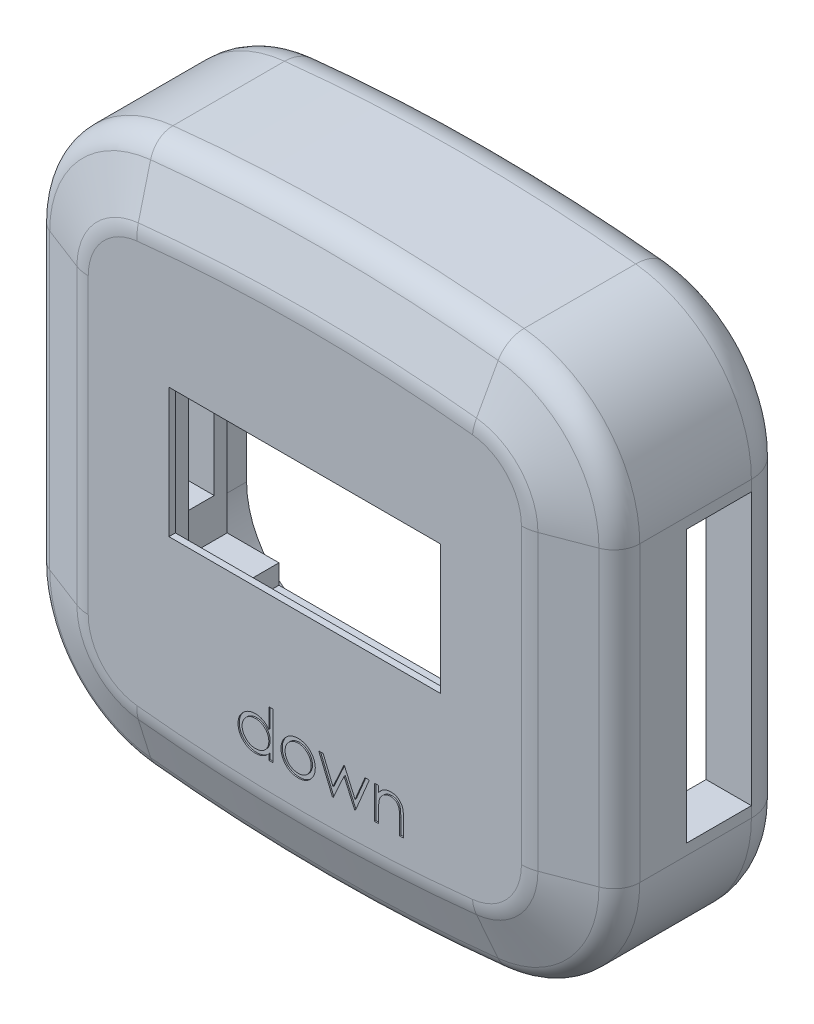
from build123d import *
from OCP.BRepFilletAPI import BRepFilletAPI_MakeChamfer

# Parameters (mm, degrees)
BOSS_EXTRU_1_DEPTH                   = 15
CONG_1_R                             = 3
CHANFREIN1_SIZE                      = 2
CHANFREIN1_SIZE2                     = 5.210178129
CONG_2_R                             = 3
CONG_3_R                             = 2
ENL_V_MAT_EXTRU_4_DEPTH              = 0.1
ESQUISSE3_W                          = 30
ESQUISSE3_H                          = 30
ENL_V_MAT_EXTRU_5_DEPTH              = 12
ESQUISSE10_W                         = 21
ESQUISSE10_H                         = 10
ENL_V_MAT_EXTRU_6_DEPTH              = 0.5
ESQUISSE9_W                          = 27
ESQUISSE9_H                          = 19.5
ENL_V_MAT_EXTRU_7_DEPTH              = 2.5
ENL_V_MAT_EXTRU_9_DEPTH              = 2
ESQUISSE15_W                         = 38
ESQUISSE15_H                         = 27
ENL_V_MAT_EXTRU_10_DEPTH             = 7
ENL_V_MAT_EXTRU_11_REACH             = 51.503
ESQUISSE16_W                         = 5
ESQUISSE16_H                         = 21
ENL_V_MAT_EXTRU_11_DIRECTION_2_REACH = 51.503


with BuildPart() as part:
    # Esquisse1 → Boss.-Extru.1 (new body)
    with BuildSketch(Plane.XY):
        with BuildLine():
            Line((-25.377842072, 10.899753086), (-25.377842072, -11.767388837))
            ThreePointArc((-25.377842072, -11.767388837), (-22.815336348, -18.451974007), (-16.441106293, -21.710701625))
            ThreePointArc((-16.441106293, -21.710701625), (-2.877842072, -22.433817876), (10.685422149, -21.710701625))
            ThreePointArc((10.685422149, -21.710701625), (17.059652204, -18.451974007), (19.622157928, -11.767388837))
            Line((19.622157928, -11.767388837), (19.622157928, 10.899753086))
            ThreePointArc((19.622157928, 10.899753086), (17.059652204, 17.584338256), (10.685422149, 20.843065874))
            ThreePointArc((10.685422149, 20.843065874), (-2.877842072, 21.566182124), (-16.441106293, 20.843065874))
            ThreePointArc((-16.441106293, 20.843065874), (-22.815336348, 17.584338256), (-25.377842072, 10.899753086))
        make_face()
    extrude(amount=BOSS_EXTRU_1_DEPTH)

    # Congé1
    cong_1_edges = [part.edges().sort_by_distance(p)[0] for p in [
        (-2.877842072, 21.566182124, 0),
        (17.059652204, 17.584338256, 0),
        (19.622157928, -0.433817876, 0),
        (17.059652204, -18.451974007, 0),
        (-2.877842072, -22.433817876, 0),
        (-22.815336348, -18.451974007, 0),
        (-25.377842072, -0.433817876, 0),
        (-22.815336348, 17.584338256, 0),
    ]]
    fillet(cong_1_edges, radius=CONG_1_R)

    # Chanfrein1: one chamfer whose edges measure the first distance from different faces: ONE call of the kernel's chamfer builder (chamfer() names one face for all edges)
    chanfrein1_edges_1 = [part.edges().sort_by_distance(p)[0] for p in [
        (-22.815336348, 17.584338256, 15),
    ]]
    chanfrein1_side_1 = [part.faces().sort_by_distance(p)[0] for p in [
        (-22.815336348, 17.584338256, 9),
    ]]
    chanfrein1_edges_2 = [part.edges().sort_by_distance(p)[0] for p in [
        (-25.377842072, -0.433817876, 15),
    ]]
    chanfrein1_side_2 = [part.faces().sort_by_distance(p)[0] for p in [
        (-25.377842072, -0.433817876, 9),
    ]]
    chanfrein1_edges_3 = [part.edges().sort_by_distance(p)[0] for p in [
        (-22.815336348, -18.451974007, 15),
    ]]
    chanfrein1_side_3 = [part.faces().sort_by_distance(p)[0] for p in [
        (-22.815336348, -18.451974007, 9),
    ]]
    chanfrein1_edges_4 = [part.edges().sort_by_distance(p)[0] for p in [
        (-2.877842072, -22.433817876, 15),
    ]]
    chanfrein1_side_4 = [part.faces().sort_by_distance(p)[0] for p in [
        (-2.877842072, -22.433817876, 9),
    ]]
    chanfrein1_edges_5 = [part.edges().sort_by_distance(p)[0] for p in [
        (17.059652204, -18.451974007, 15),
    ]]
    chanfrein1_side_5 = [part.faces().sort_by_distance(p)[0] for p in [
        (17.059652204, -18.451974007, 9),
    ]]
    chanfrein1_edges_6 = [part.edges().sort_by_distance(p)[0] for p in [
        (19.622157928, -0.433817876, 15),
    ]]
    chanfrein1_side_6 = [part.faces().sort_by_distance(p)[0] for p in [
        (19.622157928, -0.433817876, 9),
    ]]
    chanfrein1_edges_7 = [part.edges().sort_by_distance(p)[0] for p in [
        (17.059652204, 17.584338256, 15),
    ]]
    chanfrein1_side_7 = [part.faces().sort_by_distance(p)[0] for p in [
        (17.059652204, 17.584338256, 9),
    ]]
    chanfrein1_edges_8 = [part.edges().sort_by_distance(p)[0] for p in [
        (-2.877842072, 21.566182124, 15),
    ]]
    chanfrein1_side_8 = [part.faces().sort_by_distance(p)[0] for p in [
        (-2.877842072, 21.566182124, 9),
    ]]
    chanfrein1 = BRepFilletAPI_MakeChamfer(part.part.solid().wrapped)
    for e in chanfrein1_edges_1:
        chanfrein1.Add(CHANFREIN1_SIZE, CHANFREIN1_SIZE2, e.wrapped, chanfrein1_side_1[0].wrapped)  # the first distance lies on this face
    for e in chanfrein1_edges_2:
        chanfrein1.Add(CHANFREIN1_SIZE, CHANFREIN1_SIZE2, e.wrapped, chanfrein1_side_2[0].wrapped)  # the first distance lies on this face
    for e in chanfrein1_edges_3:
        chanfrein1.Add(CHANFREIN1_SIZE, CHANFREIN1_SIZE2, e.wrapped, chanfrein1_side_3[0].wrapped)  # the first distance lies on this face
    for e in chanfrein1_edges_4:
        chanfrein1.Add(CHANFREIN1_SIZE, CHANFREIN1_SIZE2, e.wrapped, chanfrein1_side_4[0].wrapped)  # the first distance lies on this face
    for e in chanfrein1_edges_5:
        chanfrein1.Add(CHANFREIN1_SIZE, CHANFREIN1_SIZE2, e.wrapped, chanfrein1_side_5[0].wrapped)  # the first distance lies on this face
    for e in chanfrein1_edges_6:
        chanfrein1.Add(CHANFREIN1_SIZE, CHANFREIN1_SIZE2, e.wrapped, chanfrein1_side_6[0].wrapped)  # the first distance lies on this face
    for e in chanfrein1_edges_7:
        chanfrein1.Add(CHANFREIN1_SIZE, CHANFREIN1_SIZE2, e.wrapped, chanfrein1_side_7[0].wrapped)  # the first distance lies on this face
    for e in chanfrein1_edges_8:
        chanfrein1.Add(CHANFREIN1_SIZE, CHANFREIN1_SIZE2, e.wrapped, chanfrein1_side_8[0].wrapped)  # the first distance lies on this face
    add(Compound.cast(chanfrein1.Shape()), mode=Mode.REPLACE)

    # Congé2
    cong_2_edges = [part.edges().sort_by_distance(p)[0] for p in [
        (13.184585203, 14.10155031, 15),
        (-2.877842072, 16.356003995, 15),
        (-18.940269346, 14.10155031, 15),
        (-20.167663943, -0.433817876, 15),
        (-18.940269346, -14.969186062, 15),
        (-2.877842072, -17.223639746, 15),
        (13.184585203, -14.969186062, 15),
        (14.411979799, -0.433817876, 15),
    ]]
    fillet(cong_2_edges, radius=CONG_2_R)

    # Congé3
    cong_3_edges = [part.edges().sort_by_distance(p)[0] for p in [
        (19.622157928, -0.433817876, 13),
        (17.059652204, -18.451974007, 13),
        (-2.877842072, -22.433817876, 13),
        (-22.815336348, -18.451974007, 13),
        (-25.377842072, -0.433817876, 13),
        (-22.815336348, 17.584338256, 13),
        (-2.877842072, 21.566182124, 13),
        (17.059652204, 17.584338256, 13),
    ]]
    fillet(cong_3_edges, radius=CONG_3_R)

    # Esquisse7 → Enlèv. mat.-Extru.4 (cut)
    with BuildSketch(Plane.XY.offset(15)):
        with BuildLine():
            Line((-5.346766398, -10.951246412), (-5.346766398, -14.540990002))
            Line((-5.346766398, -14.540990002), (-5.660868962, -14.540990002))
            Line((-5.660868962, -14.540990002), (-5.660868962, -14.098582149))
            add(Edge.make_bspline(
                [(-5.660868962, -14.098582149), (-5.696287753, -14.138621743), (-5.765407968, -14.216759514), (-5.880849086, -14.318841687), (-6.003217264, -14.403220008), (-6.131918585, -14.471369924), (-6.266836829, -14.52256198), (-6.407672916, -14.55894814), (-6.554484297, -14.582341975), (-6.654736652, -14.584677997), (-6.705540437, -14.585861797)],
                knots=[0, 0, 0, 0, 1.074387032, 2.096679803, 3.090159297, 4.057316773, 5.018401886, 5.985159533, 6.978961417, 8, 8, 8, 8], degree=3))
            add(Edge.make_bspline(
                [(-6.705540437, -14.585861797), (-6.750708391, -14.584635425), (-6.839781596, -14.582216964), (-6.970810673, -14.56345466), (-7.096902922, -14.533324039), (-7.218177495, -14.491423149), (-7.33384964, -14.435842328), (-7.444909737, -14.36930108), (-7.550782429, -14.29006025), (-7.649853968, -14.199472221), (-7.741085968, -14.101077234), (-7.821147241, -13.996131687), (-7.887900321, -13.885089383), (-7.943720401, -13.769356229), (-7.986716746, -13.64804131), (-8.01669038, -13.521564142), (-8.035430827, -13.390074268), (-8.037848288, -13.300534745), (-8.039074091, -13.25513263)],
                knots=[0, 0, 0, 0, 1.033919861, 2.038935746, 3.024066025, 3.998881131, 4.97069526, 5.957263378, 6.95902576, 7.993208707, 9.027059324, 10.027763471, 11.009749337, 11.988697705, 12.965288445, 13.950418724, 14.960734635, 16, 16, 16, 16], degree=3))
            add(Edge.make_bspline(
                [(-8.039074091, -13.25513263), (-8.037821119, -13.210668927), (-8.035344062, -13.122766583), (-8.016890843, -12.993487885), (-7.985859834, -12.868969625), (-7.942311986, -12.749612681), (-7.886470031, -12.635272631), (-7.818541944, -12.525868606), (-7.73852282, -12.421099209), (-7.646270413, -12.323427982), (-7.546335642, -12.233207368), (-7.439426912, -12.154798322), (-7.32820363, -12.087081473), (-7.21094062, -12.033427997), (-7.089373515, -11.990018892), (-6.962420069, -11.959985924), (-6.83060849, -11.942288603), (-6.741117998, -11.939725839), (-6.695724732, -11.938425899)],
                knots=[0, 0, 0, 0, 1.020392517, 2.01726096, 2.990465484, 3.961182959, 4.928053699, 5.906110375, 6.912531644, 7.948652711, 8.985773172, 9.998621852, 10.987621588, 11.969261332, 12.953316658, 13.946091881, 14.958173133, 16, 16, 16, 16], degree=3))
            add(Edge.make_bspline(
                [(-6.695724732, -11.938425899), (-6.643507924, -11.939992995), (-6.541012133, -11.943069031), (-6.391113612, -11.968775398), (-6.249326001, -12.011938276), (-6.114833014, -12.071029557), (-5.988436454, -12.147830308), (-5.869209813, -12.240581756), (-5.75922649, -12.351908902), (-5.694154668, -12.435520476), (-5.660868962, -12.478289681)],
                knots=[0, 0, 0, 0, 1.031072012, 2.023879775, 2.993683497, 3.952812103, 4.918022106, 5.908088563, 6.929940113, 8, 8, 8, 8], degree=3))
            Line((-5.660868962, -12.478289681), (-5.660868962, -10.951246412))
            Line((-5.660868962, -10.951246412), (-5.346766398, -10.951246412))
        make_face()
        with BuildLine():
            add(Edge.make_bspline(
                [(-6.691518001, -12.252528463), (-6.737432339, -12.254162101), (-6.828059939, -12.257386642), (-6.961103941, -12.282560137), (-7.088417355, -12.324444732), (-7.209363429, -12.381726633), (-7.322031646, -12.45375537), (-7.422725317, -12.540876753), (-7.512268018, -12.640713767), (-7.587576282, -12.752815877), (-7.648966779, -12.872993968), (-7.692133811, -12.998618407), (-7.720603059, -13.127423384), (-7.723511579, -13.21478607), (-7.724971527, -13.258638239)],
                knots=[0, 0, 0, 0, 1.031046209, 2.035121221, 3.029706178, 4.034933723, 5.034054252, 6.02443088, 7.017295772, 8.038157696, 9.050218397, 10.03989886, 11.016116709, 12, 12, 12, 12], degree=3))
            add(Edge.make_bspline(
                [(-7.724971527, -13.258638239), (-7.723106633, -13.302228346), (-7.719384156, -13.389237702), (-7.692633462, -13.518218279), (-7.647753589, -13.643872321), (-7.586511526, -13.765133314), (-7.509824901, -13.877717415), (-7.420936249, -13.979457537), (-7.318985967, -14.066947126), (-7.20605846, -14.140184699), (-7.08545049, -14.19934722), (-6.958616558, -14.24051286), (-6.82794092, -14.26709064), (-6.739088586, -14.270195117), (-6.694322488, -14.271759233)],
                knots=[0, 0, 0, 0, 0.979072187, 1.954306742, 2.945804271, 3.96968567, 4.997920485, 5.998718438, 6.996577872, 8.005894225, 9.015743152, 10.005417472, 10.995077863, 12, 12, 12, 12], degree=3))
            add(Edge.make_bspline(
                [(-6.694322488, -14.271759233), (-6.648875985, -14.270099269), (-6.558487399, -14.266797765), (-6.425048691, -14.2415165), (-6.295553728, -14.199747701), (-6.1717665, -14.141848575), (-6.056450369, -14.070091219), (-5.952952491, -13.986084128), (-5.865436523, -13.888380944), (-5.791243913, -13.781004491), (-5.733068496, -13.663292494), (-5.690692437, -13.537958303), (-5.665638531, -13.404997555), (-5.662480802, -13.314133628), (-5.660868962, -13.267752822)],
                knots=[0, 0, 0, 0, 1.01762866, 2.023962475, 3.030623092, 4.058876274, 5.077231937, 6.066672613, 7.034107872, 8.005628644, 8.981990164, 9.965428785, 10.961468474, 12, 12, 12, 12], degree=3))
            add(Edge.make_bspline(
                [(-5.660868962, -13.267752822), (-5.661828619, -13.232414992), (-5.663717526, -13.162858959), (-5.678148096, -13.060731441), (-5.701103022, -12.962997715), (-5.733449192, -12.869555026), (-5.775940477, -12.780920011), (-5.827188243, -12.69645625), (-5.888093692, -12.616603039), (-5.957676388, -12.542459968), (-6.033841591, -12.474833506), (-6.114436132, -12.414469265), (-6.200414879, -12.364880492), (-6.290331915, -12.323839221), (-6.38434325, -12.291180071), (-6.48321387, -12.269392377), (-6.585892857, -12.254432056), (-6.655938912, -12.253169675), (-6.691518001, -12.252528463)],
                knots=[0, 0, 0, 0, 1.050140795, 2.067009409, 3.05949893, 4.030605086, 5.00011959, 5.97591094, 6.962425594, 7.979863591, 8.993523472, 9.986985069, 10.967611495, 11.937549037, 12.921786183, 13.919465291, 14.943216303, 16, 16, 16, 16], degree=3))
        make_face(mode=Mode.SUBTRACT)
        with BuildLine():
            add(Edge.make_bspline(
                [(-3.393441078, -11.938425899), (-3.345449805, -11.93944779), (-3.251350647, -11.941451469), (-3.113542762, -11.962866435), (-2.981997626, -11.995613799), (-2.856211433, -12.040885361), (-2.737795138, -12.101567312), (-2.625023894, -12.173976603), (-2.518206885, -12.259759197), (-2.454183856, -12.326117265), (-2.42168627, -12.359800098)],
                knots=[0, 0, 0, 0, 1.054011418, 2.066658804, 3.057071809, 4.030435133, 4.997543892, 5.974964718, 6.972108034, 8, 8, 8, 8], degree=3))
            add(Edge.make_bspline(
                [(-2.42168627, -12.359800098), (-2.393704316, -12.392014084), (-2.338281936, -12.455818626), (-2.267216217, -12.559274239), (-2.205994657, -12.66641434), (-2.156931696, -12.778661666), (-2.118246672, -12.895036337), (-2.090780976, -13.015938349), (-2.074444041, -13.141100696), (-2.072241074, -13.226104534), (-2.071125373, -13.269155066)],
                knots=[0, 0, 0, 0, 1.025258237, 2.030674902, 3.01204498, 3.988269485, 4.97094183, 5.956517959, 6.965070386, 8, 8, 8, 8], degree=3))
            add(Edge.make_bspline(
                [(-2.071125373, -13.269155066), (-2.07210671, -13.312455124), (-2.074045878, -13.398018057), (-2.092389495, -13.524037423), (-2.120920581, -13.646232245), (-2.161752419, -13.764090939), (-2.214110528, -13.877973767), (-2.278001216, -13.987383316), (-2.353872833, -14.092535449), (-2.43987683, -14.192537287), (-2.534928706, -14.284703502), (-2.638044854, -14.365031772), (-2.747198888, -14.433853296), (-2.863842241, -14.489289712), (-2.986909728, -14.532999412), (-3.116666796, -14.563699429), (-3.252911866, -14.582261112), (-3.345939088, -14.584644686), (-3.393441078, -14.585861797)],
                knots=[0, 0, 0, 0, 0.998656419, 1.973391657, 2.932242238, 3.890759089, 4.846373663, 5.82037756, 6.809684879, 7.83454468, 8.860553229, 9.859544525, 10.845671541, 11.83227036, 12.833544569, 13.85385346, 14.904124723, 16, 16, 16, 16], degree=3))
            add(Edge.make_bspline(
                [(-3.393441078, -14.585861797), (-3.441175797, -14.584640601), (-3.534666657, -14.582248826), (-3.671392639, -14.563771543), (-3.801382258, -14.533013561), (-3.924610856, -14.489146068), (-4.041755703, -14.433851524), (-4.1515422, -14.365239835), (-4.254742116, -14.284679679), (-4.3498141, -14.192543742), (-4.435812706, -14.092533786), (-4.511685714, -13.987383748), (-4.57557604, -13.877973654), (-4.627934244, -13.764090969), (-4.668766057, -13.646232237), (-4.69729715, -13.524037425), (-4.715640764, -13.398018056), (-4.717579933, -13.312455123), (-4.71856127, -13.269155066)],
                knots=[0, 0, 0, 0, 1.099876186, 2.154163076, 3.173186993, 4.173200201, 5.163417411, 6.152872554, 7.150605724, 8.17532212, 9.198891216, 10.186952605, 11.159729845, 12.11414092, 13.071450619, 14.029093627, 15.002601286, 16, 16, 16, 16], degree=3))
            add(Edge.make_bspline(
                [(-4.71856127, -13.269155066), (-4.71743796, -13.22633852), (-4.715213998, -13.141569118), (-4.698893489, -13.016642057), (-4.671534933, -12.895944668), (-4.632803536, -12.780019192), (-4.583288345, -12.668263756), (-4.522927058, -12.560858925), (-4.451136425, -12.457871125), (-4.395934473, -12.394149044), (-4.368000373, -12.361903463)],
                knots=[0, 0, 0, 0, 1.031353054, 2.041901799, 3.029428768, 4.008703097, 4.981709435, 5.96992636, 6.972712378, 8, 8, 8, 8], degree=3))
            add(Edge.make_bspline(
                [(-4.368000373, -12.361903463), (-4.335551782, -12.327928524), (-4.271735918, -12.261110828), (-4.16438719, -12.175578304), (-4.051893369, -12.10166223), (-3.932168443, -12.042186015), (-3.806485585, -11.995347497), (-3.674266342, -11.962781982), (-3.535990827, -11.941528627), (-3.441431206, -11.939470449), (-3.393441078, -11.938425899)],
                knots=[0, 0, 0, 0, 1.027980169, 2.021703884, 2.998553061, 3.971491411, 4.943284454, 5.930300938, 6.949603206, 8, 8, 8, 8], degree=3))
        make_face()
        with BuildLine():
            add(Edge.make_bspline(
                [(-3.394843321, -12.252528463), (-3.428780933, -12.253493055), (-3.495780061, -12.255397338), (-3.594399646, -12.269881242), (-3.6893398, -12.292828746), (-3.780780644, -12.325432803), (-3.868413817, -12.367531702), (-3.952323219, -12.419240062), (-4.032755659, -12.479873018), (-4.108137722, -12.54933569), (-4.177320034, -12.625214684), (-4.237798011, -12.706063043), (-4.289223117, -12.79056939), (-4.332063276, -12.878821601), (-4.363970464, -12.971714015), (-4.387143487, -13.068194646), (-4.401613727, -13.168460062), (-4.403500106, -13.236621081), (-4.404458706, -13.271258431)],
                knots=[0, 0, 0, 0, 1.021534396, 2.016698045, 2.994645724, 3.958388632, 4.93408049, 5.916473867, 6.921342795, 7.962252576, 8.998418191, 10.008913653, 10.997312074, 11.973003931, 12.956656626, 13.948281152, 14.957379055, 16, 16, 16, 16], degree=3))
            add(Edge.make_bspline(
                [(-4.404458706, -13.271258431), (-4.402851882, -13.316010459), (-4.399662638, -13.404834864), (-4.373727402, -13.535645987), (-4.330341122, -13.661227839), (-4.271753842, -13.780844225), (-4.198347623, -13.891516503), (-4.111860557, -13.990187987), (-4.013220856, -14.075373799), (-3.903604356, -14.146054644), (-3.785250038, -14.2022144), (-3.659993717, -14.242013376), (-3.529353023, -14.267885068), (-3.440072292, -14.270456542), (-3.394843321, -14.271759233)],
                knots=[0, 0, 0, 0, 1.016792936, 2.018143844, 3.017858371, 4.030088057, 5.03801393, 6.028138512, 7.003788237, 7.991172063, 8.984598303, 9.972568034, 10.972917682, 12, 12, 12, 12], degree=3))
            add(Edge.make_bspline(
                [(-3.394843321, -14.271759233), (-3.349616953, -14.270448952), (-3.260341357, -14.267862496), (-3.12988218, -14.242143676), (-3.004968208, -14.202040015), (-2.88673682, -14.146117805), (-2.777170217, -14.07510539), (-2.677821096, -13.990669013), (-2.592072484, -13.891255162), (-2.51873888, -13.780697633), (-2.459192137, -13.661413281), (-2.416008935, -13.535622809), (-2.390011349, -13.404840767), (-2.38683052, -13.316012436), (-2.385227937, -13.271258431)],
                knots=[0, 0, 0, 0, 1.02726834, 2.027799167, 3.010890988, 4.004497153, 4.992059811, 5.971914811, 6.958719428, 7.966827853, 8.981595046, 9.981490638, 10.983022906, 12, 12, 12, 12], degree=3))
            add(Edge.make_bspline(
                [(-2.385227937, -13.271258431), (-2.386186207, -13.236620874), (-2.388071936, -13.168459448), (-2.4025469, -13.068196994), (-2.42570244, -12.971705398), (-2.457674057, -12.878853395), (-2.500328071, -12.79034089), (-2.552744864, -12.706311163), (-2.61297589, -12.624934617), (-2.682993011, -12.549580976), (-2.758296388, -12.47984594), (-2.838761427, -12.41921655), (-2.922546405, -12.367758955), (-3.009924988, -12.325072714), (-3.101377555, -12.293125374), (-3.196184685, -12.269748742), (-3.294383495, -12.255458546), (-3.361142538, -12.253511404), (-3.394843321, -12.252528463)],
                knots=[0, 0, 0, 0, 1.042956736, 2.052379634, 3.044323526, 4.02829302, 5.004299113, 5.996692471, 7.007513377, 8.048758398, 9.090003419, 10.095195979, 11.07790575, 12.047570684, 13.018257071, 13.989683339, 14.985167495, 16, 16, 16, 16], degree=3))
        make_face(mode=Mode.SUBTRACT)
        Polygon((-1.801894604, -11.983297694), (-1.46465502, -11.983297694), (-0.702535629, -13.823041284), (0.132500429, -11.983297694), (0.185785685, -11.983297694), (1.002592576, -13.823041284), (1.771723185, -11.983297694), (2.10195155, -11.983297694), (1.032740813, -14.540990002), (0.967536486, -14.540990002), (0.150028473, -12.701246412), (-0.684306462, -14.540990002), (-0.742499571, -14.540990002), align=None)
        with BuildLine():
            Line((2.505797704, -11.983297694), (2.819900268, -11.983297694))
            Line((2.819900268, -11.983297694), (2.819900268, -12.444635835))
            add(Edge.make_bspline(
                [(2.819900268, -12.444635835), (2.853437903, -12.402793112), (2.918518854, -12.321595849), (3.026903188, -12.214875274), (3.141447088, -12.126930049), (3.261449092, -12.056826255), (3.387072102, -12.003979629), (3.517550372, -11.965813698), (3.653665078, -11.94292887), (3.746229515, -11.939938639), (3.79305732, -11.938425899)],
                knots=[0, 0, 0, 0, 1.12780773, 2.188550248, 3.19190651, 4.159438251, 5.104880172, 6.052711206, 7.014878035, 8, 8, 8, 8], degree=3))
            add(Edge.make_bspline(
                [(3.79305732, -11.938425899), (3.840387954, -11.940171095), (3.933025421, -11.943586863), (4.067903483, -11.970603554), (4.193876877, -12.016748809), (4.310496432, -12.07996088), (4.415623646, -12.158567353), (4.507948497, -12.250145135), (4.584311745, -12.355481218), (4.635509108, -12.453204374), (4.669234755, -12.539893169), (4.690467093, -12.614139919), (4.708498074, -12.69685807), (4.724129822, -12.787797659), (4.734706934, -12.887595849), (4.743049226, -12.995843541), (4.74902792, -13.112505672), (4.749265127, -13.193192299), (4.749387448, -13.234800098)],
                knots=[0, 0, 0, 0, 1.235846778, 2.418850247, 3.575807741, 4.728682307, 5.871620074, 6.994088408, 8.11269785, 9.256955736, 9.865816715, 10.540099792, 11.271859618, 12.076849838, 12.949306005, 13.892391288, 14.913166135, 16, 16, 16, 16], degree=3))
            Line((4.749387448, -13.234800098), (4.749387448, -14.540990002))
            Line((4.749387448, -14.540990002), (4.435284884, -14.540990002))
            Line((4.435284884, -14.540990002), (4.435284884, -13.337865002))
            add(Edge.make_bspline(
                [(4.435284884, -13.337865002), (4.435091676, -13.303042557), (4.434722102, -13.236433146), (4.433556455, -13.141064123), (4.430746648, -13.054577545), (4.426798335, -12.977180177), (4.421019305, -12.908946341), (4.414996673, -12.849737064), (4.407631697, -12.799627521), (4.401068784, -12.769462439), (4.398125429, -12.755933912)],
                knots=[0, 0, 0, 0, 1.430800155, 2.736877192, 3.918605307, 4.986035426, 5.920637409, 6.731861385, 7.431261377, 8, 8, 8, 8], degree=3))
            add(Edge.make_bspline(
                [(4.398125429, -12.755933912), (4.387499897, -12.716222727), (4.367049036, -12.639790983), (4.316515053, -12.53611663), (4.252700872, -12.447918442), (4.174803023, -12.375741721), (4.083573947, -12.319570884), (3.979266805, -12.280596929), (3.862888164, -12.25622066), (3.781033781, -12.253793528), (3.73836982, -12.252528463)],
                knots=[0, 0, 0, 0, 1.084156227, 2.086665306, 3.027808233, 3.945421172, 4.874247719, 5.839848303, 6.874090471, 8, 8, 8, 8], degree=3))
            add(Edge.make_bspline(
                [(3.73836982, -12.252528463), (3.713102136, -12.253004468), (3.663098043, -12.253946469), (3.588948071, -12.263397767), (3.517023898, -12.278856223), (3.446603689, -12.29972486), (3.379095895, -12.328387129), (3.312331604, -12.3609165), (3.24882484, -12.401464712), (3.187221443, -12.446655333), (3.129908635, -12.49673454), (3.076580297, -12.54957905), (3.029042276, -12.605854654), (2.985973601, -12.664654602), (2.948795338, -12.72678644), (2.91634225, -12.791650746), (2.888806555, -12.859332895), (2.875123862, -12.906307956), (2.868277672, -12.929812117)],
                knots=[0, 0, 0, 0, 1.023777757, 2.026029729, 3.023749952, 4.003683103, 4.997618607, 5.993177895, 7.010360494, 8.046726602, 9.087585522, 10.09234134, 11.086953743, 12.070360549, 13.043493632, 14.017870808, 15.008233677, 16, 16, 16, 16], degree=3))
            add(Edge.make_bspline(
                [(2.868277672, -12.929812117), (2.864338024, -12.94706732), (2.855761615, -12.984630995), (2.846498435, -13.046275414), (2.838090859, -13.117585389), (2.831053901, -13.198477706), (2.826748484, -13.289235581), (2.822054088, -13.389471419), (2.820345026, -13.499584907), (2.820052672, -13.5762466), (2.819900268, -13.616210354)],
                knots=[0, 0, 0, 0, 0.615963638, 1.340920617, 2.168419149, 3.115676021, 4.16674242, 5.331190069, 6.6087489, 8, 8, 8, 8], degree=3))
            Line((2.819900268, -13.616210354), (2.819900268, -14.540990002))
            Line((2.819900268, -14.540990002), (2.505797704, -14.540990002))
            Line((2.505797704, -14.540990002), (2.505797704, -11.983297694))
        make_face()
    extrude(amount=-ENL_V_MAT_EXTRU_4_DEPTH, mode=Mode.SUBTRACT)

    # Esquisse3 → Enlèv. mat.-Extru.5 (cut)
    with BuildSketch(Plane(origin=(0, 0, 0), x_dir=(-1, 0, 0), z_dir=(0, 0, -1))):
        with Locations((2.877842072, -0.433817876)):
            Rectangle(ESQUISSE3_W, ESQUISSE3_H)
    extrude(amount=-ENL_V_MAT_EXTRU_5_DEPTH, mode=Mode.SUBTRACT)

    # Esquisse10 → Enlèv. mat.-Extru.6 (cut)
    with BuildSketch(Plane.XY.offset(15)):
        with Locations((-2.877842072, 1.566182124)):
            Rectangle(ESQUISSE10_W, ESQUISSE10_H)
    extrude(amount=-ENL_V_MAT_EXTRU_6_DEPTH, mode=Mode.SUBTRACT)

    # Esquisse9 → Enlèv. mat.-Extru.7 (cut)
    with BuildSketch(Plane(origin=(0, 0, 12), x_dir=(-1, 0, 0), z_dir=(0, 0, -1))):
        with Locations((2.877842072, -0.583817876)):
            Rectangle(ESQUISSE9_W, ESQUISSE9_H)
    extrude(amount=-ENL_V_MAT_EXTRU_7_DEPTH, mode=Mode.SUBTRACT)

    # Esquisse14 → Enlèv. mat.-Extru.9 (cut)
    with BuildSketch(Plane(origin=(0, 0, 0), x_dir=(-1, 0, 0), z_dir=(0, 0, -1))):
        with BuildLine():
            Line((-16.622157928, 10.899753086), (-16.622157928, -11.767388837))
            ThreePointArc((-16.622157928, -11.767388837), (-14.828403921, -16.446598456), (-10.366442883, -18.727707789))
            ThreePointArc((-10.366442883, -18.727707789), (2.877842072, -19.433817876), (16.122127027, -18.727707789))
            ThreePointArc((16.122127027, -18.727707789), (20.584088065, -16.446598456), (22.377842072, -11.767388837))
            Line((22.377842072, -11.767388837), (22.377842072, 10.899753086))
            ThreePointArc((22.377842072, 10.899753086), (20.584088065, 15.578962705), (16.122127027, 17.860072037))
            ThreePointArc((16.122127027, 17.860072037), (2.877842072, 18.566182124), (-10.366442883, 17.860072037))
            ThreePointArc((-10.366442883, 17.860072037), (-14.828403921, 15.578962705), (-16.622157928, 10.899753086))
        make_face()
    extrude(amount=-ENL_V_MAT_EXTRU_9_DEPTH, mode=Mode.SUBTRACT)

    # Esquisse15 → Enlèv. mat.-Extru.10 (cut)
    with BuildSketch(Plane(origin=(0, 0, 2), x_dir=(-1, 0, 0), z_dir=(0, 0, -1))):
        with Locations((2.877842072, -0.433817876)):
            Rectangle(ESQUISSE15_W, ESQUISSE15_H)
    extrude(amount=-ENL_V_MAT_EXTRU_10_DEPTH, mode=Mode.SUBTRACT)

    # Enlèv. mat.-Extru.11: up to this face of the body (flat: up to its plane)
    enl_v_mat_extru_11_end = Plane(part.part.faces().sort_by_distance((-25.377842072, -0.433817876, 7.312719041))[0])
    # Esquisse16 → Enlèv. mat.-Extru.11 (cut, up to the picked face)
    with BuildSketch(Plane(origin=(-21.877842072, 0, 0), x_dir=(0, 0, -1), z_dir=(1, 0, 0)), mode=Mode.PRIVATE) as enl_v_mat_extru_11_sk1:
        with Locations((-5.5, -0.433817876)):
            Rectangle(ESQUISSE16_W, ESQUISSE16_H)
    enl_v_mat_extru_11_tool1 = split(extrude(enl_v_mat_extru_11_sk1.sketch, amount=-ENL_V_MAT_EXTRU_11_REACH, mode=Mode.PRIVATE), bisect_by=enl_v_mat_extru_11_end, keep=Keep.BOTH, mode=Mode.PRIVATE)
    add(enl_v_mat_extru_11_tool1.solids().sort_by(Axis((-21.877842, -0.433818, 5.5), (-1, 0, 0)))[0], mode=Mode.SUBTRACT)

    # Enlèv. mat.-Extru.11 direction 2: up to this face of the body (flat: up to its plane)
    enl_v_mat_extru_11_direction_2_end = Plane(part.part.faces().sort_by_distance((19.622157928, -0.433817876, 7.312719041))[0])
    # Esquisse16 → Enlèv. mat.-Extru.11 direction 2 (cut, up to the picked face)
    with BuildSketch(Plane(origin=(-21.877842072, 0, 0), x_dir=(0, 0, -1), z_dir=(1, 0, 0)), mode=Mode.PRIVATE) as enl_v_mat_extru_11_direction_2_sk1:
        with Locations((-5.5, -0.433817876)):
            Rectangle(ESQUISSE16_W, ESQUISSE16_H)
    enl_v_mat_extru_11_direction_2_tool1 = split(extrude(enl_v_mat_extru_11_direction_2_sk1.sketch, amount=ENL_V_MAT_EXTRU_11_DIRECTION_2_REACH, mode=Mode.PRIVATE), bisect_by=enl_v_mat_extru_11_direction_2_end, keep=Keep.BOTH, mode=Mode.PRIVATE)
    add(enl_v_mat_extru_11_direction_2_tool1.solids().sort_by(Axis((-21.877842, -0.433818, 5.5), (1, 0, 0)))[0], mode=Mode.SUBTRACT)


solid = part.part
